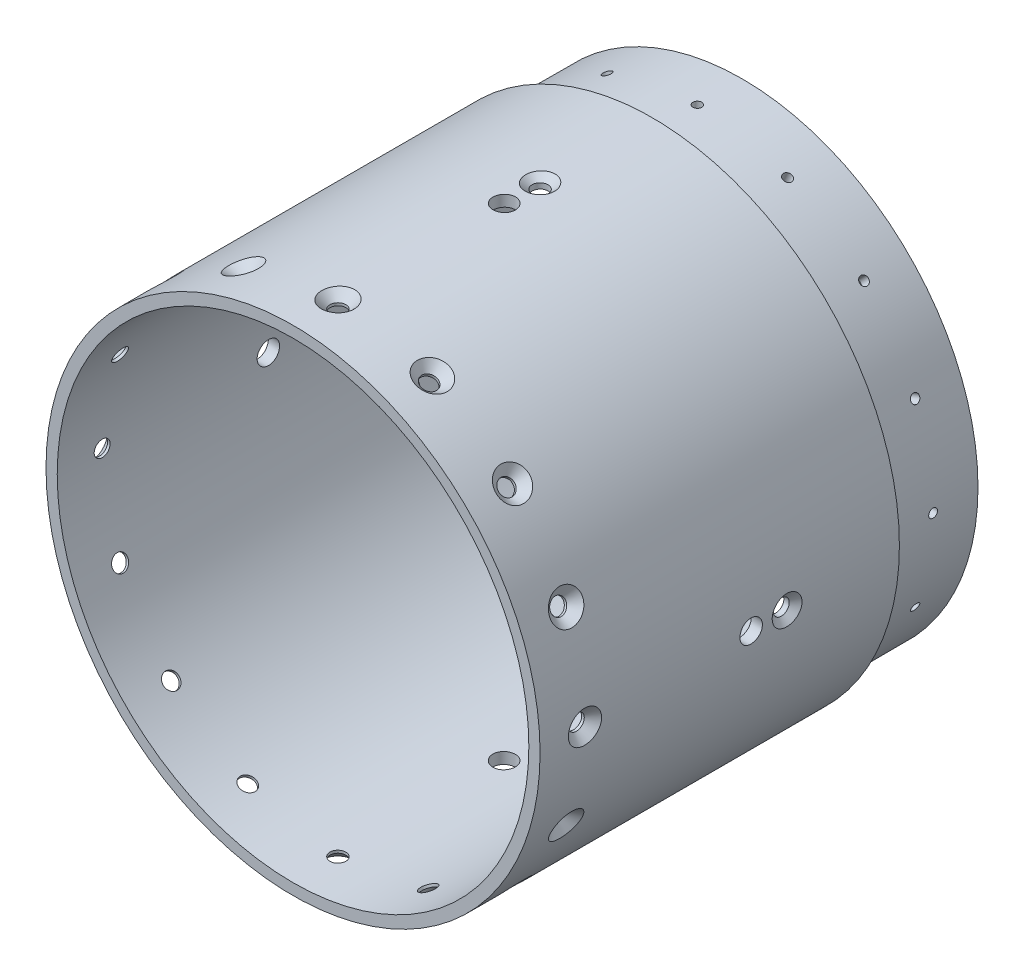
from build123d import *

# Parameters (mm, degrees)
SKETCH1_R         = 69.85
SKETCH1_R_2       = 63.5
EXTRUDE1_DEPTH    = 127
SKETCH4_OUTSIDE_W = 188.672
SKETCH4_OUTSIDE_H = 188.672
SKETCH4_OUTSIDE_R = 66.675
EXTRUDE2_DEPTH    = 25.4
SKETCH5_R         = 66.675
EXTRUDE3_DEPTH    = 95.25
CIRPATTERN1_COUNT = 16
CIRPATTERN2_COUNT = 4


with BuildPart() as part:
    # Sketch1 → Extrude1 (new body)
    with BuildSketch(Plane.XY):
        Circle(SKETCH1_R)
        Circle(SKETCH1_R_2, mode=Mode.SUBTRACT)
    extrude(amount=EXTRUDE1_DEPTH)

    # Sketch4 outside → Extrude2 (cut)
    with BuildSketch(Plane(origin=(0, 0, 0), x_dir=(-1, 0, 0), z_dir=(0, 0, -1))):
        Rectangle(SKETCH4_OUTSIDE_W, SKETCH4_OUTSIDE_H)
        Circle(SKETCH4_OUTSIDE_R, mode=Mode.SUBTRACT)
    extrude(amount=-EXTRUDE2_DEPTH, mode=Mode.SUBTRACT)

    # Sketch5 → Extrude3 (cut)
    with BuildSketch(Plane.XY.offset(127)):
        Circle(SKETCH5_R)
    extrude(amount=-EXTRUDE3_DEPTH, mode=Mode.SUBTRACT)

    # Sketch9 → #40 (0.098) Diameter Hole2 (revolve, cut)
    with BuildSketch(Plane(origin=(-66.675, 0, 12.7), x_dir=(0, 0, 1), z_dir=(0, 1, 0))):
        Polygon((0, 0), (0, 13.447831126), (1.2446, 12.7), (1.2446, 0), align=None)
    f_40_0_098_diameter_hole2 = revolve(axis=Axis((-73.025, 0, 12.7), (1, 0, 0)), mode=Mode.SUBTRACT)

    # Sketch12 → CSK for M4 Flat Head Machine Screw1 (revolve, cut)
    with BuildSketch(Plane(origin=(69.85, 0, 114.3), x_dir=(0, 0, -1), z_dir=(0, 1, 0))):
        Polygon((0, 0), (0, 13.543936393), (2.25, 12.192), (2.25, 2.45), (4.7, 0), align=None)
    csk_for_m4_flat_head_machine_screw1 = revolve(axis=Axis((76.2, 0, 114.3), (-1, 0, 0)), mode=Mode.SUBTRACT)

    # CirPattern1: #40 (0.098) Diameter Hole2, CSK for M4 Flat Head Machine Screw1 ×16 about axis
    cirpattern1_axis = Axis((0, 0, 127), (0, 0, -1))
    for i in range(1, CIRPATTERN1_COUNT):
        add(f_40_0_098_diameter_hole2.rotate(cirpattern1_axis, i * 360 / CIRPATTERN1_COUNT), mode=Mode.SUBTRACT)
        add(csk_for_m4_flat_head_machine_screw1.rotate(cirpattern1_axis, i * 360 / CIRPATTERN1_COUNT), mode=Mode.SUBTRACT)

    # Sketch17 → E (0.25) Diameter Hole2 (revolve, cut)
    with BuildSketch(Plane(origin=(0, -69.85, 67.31), x_dir=(0, 0, -1), z_dir=(1, 0, 0))):
        Polygon((0, 0), (0, 14.607732465), (3.175, 12.7), (3.175, 0), align=None)
    e_0_25_diameter_hole2 = revolve(axis=Axis((0, -76.2, 67.31), (0, 1, 0)), mode=Mode.SUBTRACT)

    # Sketch22 → CSK for #8 Flat Head Machine Screw (100)2 (revolve, cut)
    with BuildSketch(Plane(origin=(0, -69.85, 57.15), x_dir=(0, 0, -1), z_dir=(1, 0, 0))):
        Polygon((0, 0), (0, 13.542674586), (2.2479, 12.192), (2.2479, 1.651767624), (4.2164, 0), align=None)
    csk_for_8_flat_head_machine_screw_100 = revolve(axis=Axis((0, -76.2, 57.15), (0, 1, 0)), mode=Mode.SUBTRACT)

    # CirPattern2: E (0.25) Diameter Hole2, CSK for #8 Flat Head Machine Screw (100)2 ×4 about axis
    cirpattern2_axis = Axis((0, 0, 127), (0, 0, -1))
    for i in range(1, CIRPATTERN2_COUNT):
        add(e_0_25_diameter_hole2.rotate(cirpattern2_axis, i * 360 / CIRPATTERN2_COUNT), mode=Mode.SUBTRACT)
        add(csk_for_8_flat_head_machine_screw_100.rotate(cirpattern2_axis, i * 360 / CIRPATTERN2_COUNT), mode=Mode.SUBTRACT)


solid = part.part
